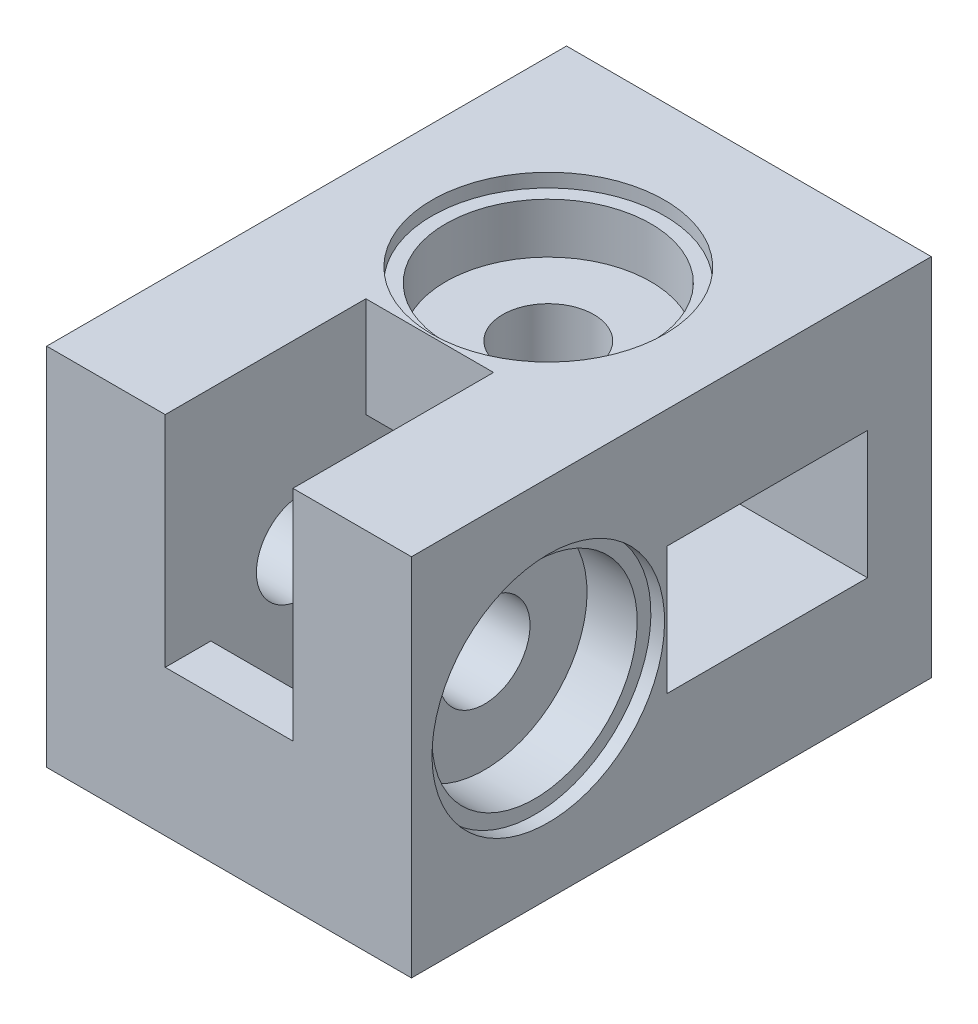
from build123d import *

# Parameters (mm, degrees)
ESQUISSE1_W              = 40
ESQUISSE1_H              = 40
BOSS_EXTRU_1_DEPTH       = 50
ESQUISSE2_R              = 5
ENL_V_MAT_EXTRU_1_DEPTH  = 41
ESQUISSE3_R              = 5
ENL_V_MAT_EXTRU_2_DEPTH  = 41
ESQUISSE4_W              = 20
ESQUISSE4_H              = 14
ENL_V_MAT_EXTRU_3_DEPTH  = 29
ESQUISSE5_W              = 14
ESQUISSE5_H              = 20
ENL_V_MAT_EXTRU_4_DEPTH  = 29
ESQUISSE6_W              = 22
ESQUISSE6_H              = 14
ENL_V_MAT_EXTRU_5_DEPTH  = 24
ESQUISSE7_W              = 14
ESQUISSE7_H              = 22
ENL_V_MAT_EXTRU_6_DEPTH  = 24
ESQUISSE8_R              = 11.25
ENL_V_MAT_EXTRU_7_DEPTH  = 7
ESQUISSE9_R              = 12.75
ENL_V_MAT_EXTRU_8_DEPTH  = 1.5
ESQUISSE10_R             = 11.25
ENL_V_MAT_EXTRU_9_DEPTH  = 7
ESQUISSE11_R             = 12.75
ENL_V_MAT_EXTRU_10_DEPTH = 1.5
ESQUISSE12_W             = 40
ESQUISSE12_H             = 40
BOSS_EXTRU_2_DEPTH       = 7
ESQUISSE13_R             = 2.25
ENL_V_MAT_EXTRU_11_DEPTH = 15
ESQUISSE14_W             = 3.5
ESQUISSE14_H             = 7.5
ENL_V_MAT_EXTRU_12_DEPTH = 12
ESQUISSE15_W             = 7.5
ESQUISSE15_H             = 3.5
ENL_V_MAT_EXTRU_13_DEPTH = 12


with BuildPart() as part:
    # Esquisse1 → Boss.-Extru.1 (new body)
    with BuildSketch(Plane.XY):
        with Locations((-20, 20)):
            Rectangle(ESQUISSE1_W, ESQUISSE1_H)
    extrude(amount=BOSS_EXTRU_1_DEPTH)

    # Esquisse2 → Enlèv. mat.-Extru.1 (cut, through all)
    with BuildSketch(Plane(origin=(0, 40, 0), x_dir=(1, 0, 0), z_dir=(0, 1, 0))):
        with Locations(Location((-20, -15, 0), (0, 0, 270))):  # turned: the seam where the file's is
            Circle(ESQUISSE2_R)
    extrude(amount=-ENL_V_MAT_EXTRU_1_DEPTH, mode=Mode.SUBTRACT)

    # Esquisse3 → Enlèv. mat.-Extru.2 (cut, through all)
    with BuildSketch(Plane.ZY.offset(40)):
        with Locations((35, 20)):
            Circle(ESQUISSE3_R)
    extrude(amount=-ENL_V_MAT_EXTRU_2_DEPTH, mode=Mode.SUBTRACT)

    # Esquisse4 → Enlèv. mat.-Extru.3 (cut)
    with BuildSketch(Plane.ZY.offset(40)):
        with Locations((15, 20)):
            Rectangle(ESQUISSE4_W, ESQUISSE4_H)
    extrude(amount=-ENL_V_MAT_EXTRU_3_DEPTH, mode=Mode.SUBTRACT)

    # Esquisse5 → Enlèv. mat.-Extru.4 (cut)
    with BuildSketch(Plane.XZ):
        with Locations((-20, 35)):
            Rectangle(ESQUISSE5_W, ESQUISSE5_H)
    extrude(amount=-ENL_V_MAT_EXTRU_4_DEPTH, mode=Mode.SUBTRACT)

    # Esquisse6 → Enlèv. mat.-Extru.5 (cut)
    with BuildSketch(Plane(origin=(0, 0, 0), x_dir=(0, 0, -1), z_dir=(1, 0, 0))):
        with Locations((-11, 20)):
            Rectangle(ESQUISSE6_W, ESQUISSE6_H)
    extrude(amount=-ENL_V_MAT_EXTRU_5_DEPTH, mode=Mode.SUBTRACT)

    # Esquisse7 → Enlèv. mat.-Extru.6 (cut)
    with BuildSketch(Plane(origin=(0, 40, 0), x_dir=(1, 0, 0), z_dir=(0, 1, 0))):
        with Locations((-20, -39)):
            Rectangle(ESQUISSE7_W, ESQUISSE7_H)
    extrude(amount=-ENL_V_MAT_EXTRU_6_DEPTH, mode=Mode.SUBTRACT)

    # Esquisse8 → Enlèv. mat.-Extru.7 (cut)
    with BuildSketch(Plane(origin=(0, 0, 0), x_dir=(0, 0, -1), z_dir=(1, 0, 0))):
        with Locations(Location((-35, 20, 0), (0, 0, 90))):  # turned: the seam where the file's is
            Circle(ESQUISSE8_R)
    extrude(amount=-ENL_V_MAT_EXTRU_7_DEPTH, mode=Mode.SUBTRACT)

    # Esquisse9 → Enlèv. mat.-Extru.8 (cut)
    with BuildSketch(Plane(origin=(0, 0, 0), x_dir=(0, 0, -1), z_dir=(1, 0, 0))):
        with Locations(Location((-35, 20, 0), (0, 0, 90))):  # turned: the seam where the file's is
            Circle(ESQUISSE9_R)
    extrude(amount=-ENL_V_MAT_EXTRU_8_DEPTH, mode=Mode.SUBTRACT)

    # Esquisse10 → Enlèv. mat.-Extru.9 (cut)
    with BuildSketch(Plane(origin=(0, 40, 0), x_dir=(1, 0, 0), z_dir=(0, 1, 0))):
        with Locations(Location((-20, -15, 0), (0, 0, 270))):  # turned: the seam where the file's is
            Circle(ESQUISSE10_R)
    extrude(amount=-ENL_V_MAT_EXTRU_9_DEPTH, mode=Mode.SUBTRACT)

    # Esquisse11 → Enlèv. mat.-Extru.10 (cut)
    with BuildSketch(Plane(origin=(0, 40, 0), x_dir=(1, 0, 0), z_dir=(0, 1, 0))):
        with Locations(Location((-20, -15, 0), (0, 0, 270))):  # turned: the seam where the file's is
            Circle(ESQUISSE11_R)
    extrude(amount=-ENL_V_MAT_EXTRU_10_DEPTH, mode=Mode.SUBTRACT)

    # Esquisse12 → Boss.-Extru.2 (add)
    with BuildSketch(Plane(origin=(0, 0, 0), x_dir=(-1, 0, 0), z_dir=(0, 0, -1))):
        with Locations((20, 20)):
            Rectangle(ESQUISSE12_W, ESQUISSE12_H)
    extrude(amount=BOSS_EXTRU_2_DEPTH)

    # Esquisse13 → Enlèv. mat.-Extru.11 (cut)
    with BuildSketch(Plane(origin=(0, 0, -7), x_dir=(-1, 0, 0), z_dir=(0, 0, -1))):
        with Locations((10, 7.5)):
            Circle(ESQUISSE13_R)
        with Locations((32.5, 30)):
            Circle(ESQUISSE13_R)
    extrude(amount=-ENL_V_MAT_EXTRU_11_DEPTH, mode=Mode.SUBTRACT)

    # Esquisse14 → Enlèv. mat.-Extru.12 (cut)
    with BuildSketch(Plane.ZY.offset(40)):
        with Locations((-1.25, 30)):
            Rectangle(ESQUISSE14_W, ESQUISSE14_H)
    extrude(amount=-ENL_V_MAT_EXTRU_12_DEPTH, mode=Mode.SUBTRACT)

    # Esquisse15 → Enlèv. mat.-Extru.13 (cut)
    with BuildSketch(Plane.XZ):
        with Locations((-10, -1.25)):
            Rectangle(ESQUISSE15_W, ESQUISSE15_H)
    extrude(amount=-ENL_V_MAT_EXTRU_13_DEPTH, mode=Mode.SUBTRACT)


solid = part.part
